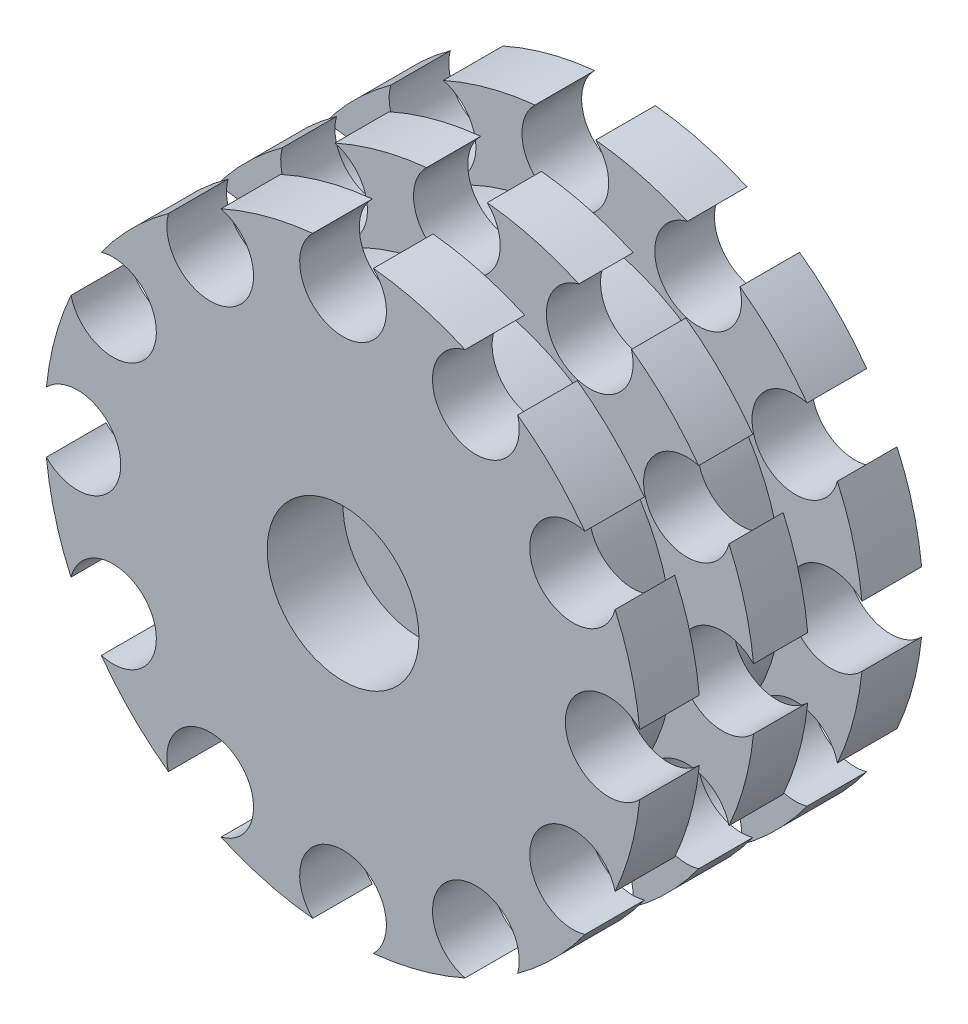
from build123d import *

# Parameters (mm, degrees)
CORTAR_EXTRUIR1_DEPTH   = 9
CROQUIS5_R              = 4
CORTAR_EXTRUIR3_DEPTH   = 27
CROQUIS6_R              = 2
CORTAR_EXTRUIR4_DEPTH   = 10
CROQUIS7_R              = 2
SALIENTE_EXTRUIR1_DEPTH = 3.5
CROQUIS8_R              = 7
CROQUIS8_R_2            = 2
CORTAR_EXTRUIR5_DEPTH   = 3.5


with BuildPart() as part:
    # Croquis1 → Revolución1 (revolve)
    with BuildSketch(Plane(origin=(0, 0, 0), x_dir=(1, 0, 0), z_dir=(0, 1, 0))):
        Polygon((0, 1.5), (0, -9.5), (7, -9.5), (7, -13), (12.5, -13), (27.5, -13), (27.5, -7.5), (20, -7.5), (20, -2.5), (27.5, -2.5), (27.5, 2.5), (20, 2.5), (20, 7.5), (27.5, 7.5), (27.5, 13), (12.5, 13), (12.5, 6.5), (7.5, 1.5), align=None)
    revolve(axis=Axis((0, 0, 0), (0, 0, -1)))

    # Croquis2 → Cortar-Extruir1 (cut)
    with BuildSketch(Plane(origin=(0, 0, -1.5), x_dir=(-1, 0, 0), z_dir=(0, 0, -1))):
        Polygon((7.505553499, 0), (3.75277675, 6.5), (-3.75277675, 6.5), (-7.505553499, 0), (-3.75277675, -6.5), (3.75277675, -6.5), align=None)
    extrude(amount=-CORTAR_EXTRUIR1_DEPTH, mode=Mode.SUBTRACT)

    # Croquis5 → Cortar-Extruir3 (cut, through all)
    with BuildSketch(Plane.XY.offset(13)):
        with Locations((0, 24.5)):
            Circle(CROQUIS5_R)
        with Locations((12.25, 21.217622393)):
            Circle(CROQUIS5_R)
        with Locations((21.217622393, 12.25)):
            Circle(CROQUIS5_R)
        with Locations((24.5, 0)):
            Circle(CROQUIS5_R)
        with Locations((21.217622393, -12.25)):
            Circle(CROQUIS5_R)
        with Locations((12.25, -21.217622393)):
            Circle(CROQUIS5_R)
        with Locations((0, -24.5)):
            Circle(CROQUIS5_R)
        with Locations((-12.25, -21.217622393)):
            Circle(CROQUIS5_R)
        with Locations((-21.217622393, -12.25)):
            Circle(CROQUIS5_R)
        with Locations((-24.5, 0)):
            Circle(CROQUIS5_R)
        with Locations((-21.217622393, 12.25)):
            Circle(CROQUIS5_R)
        with Locations((-12.25, 21.217622393)):
            Circle(CROQUIS5_R)
    extrude(amount=-CORTAR_EXTRUIR3_DEPTH, mode=Mode.SUBTRACT)

    # Croquis6 → Cortar-Extruir4 (cut)
    with BuildSketch(Plane(origin=(0, 0, 7.5), x_dir=(-1, 0, 0), z_dir=(0, 0, -1))):
        Circle(CROQUIS6_R)
    extrude(amount=-CORTAR_EXTRUIR4_DEPTH, mode=Mode.SUBTRACT)

    # Croquis7 → Saliente-Extruir1 (add)
    with BuildSketch(Plane(origin=(0, 0, 7.5), x_dir=(-1, 0, 0), z_dir=(0, 0, -1))):
        Polygon((3.75277675, -6.5), (7.505553499, 0), (3.75277675, 6.5), (-3.75277675, 6.5), (-7.505553499, 0), (-3.75277675, -6.5), align=None)
        Circle(CROQUIS7_R, mode=Mode.SUBTRACT)
    extrude(amount=SALIENTE_EXTRUIR1_DEPTH)

    # Croquis8 → Cortar-Extruir5 (cut)
    with BuildSketch(Plane.XY.offset(9.5)):
        Circle(CROQUIS8_R)
        Circle(CROQUIS8_R_2, mode=Mode.SUBTRACT)
    extrude(amount=-CORTAR_EXTRUIR5_DEPTH, mode=Mode.SUBTRACT)


solid = part.part
